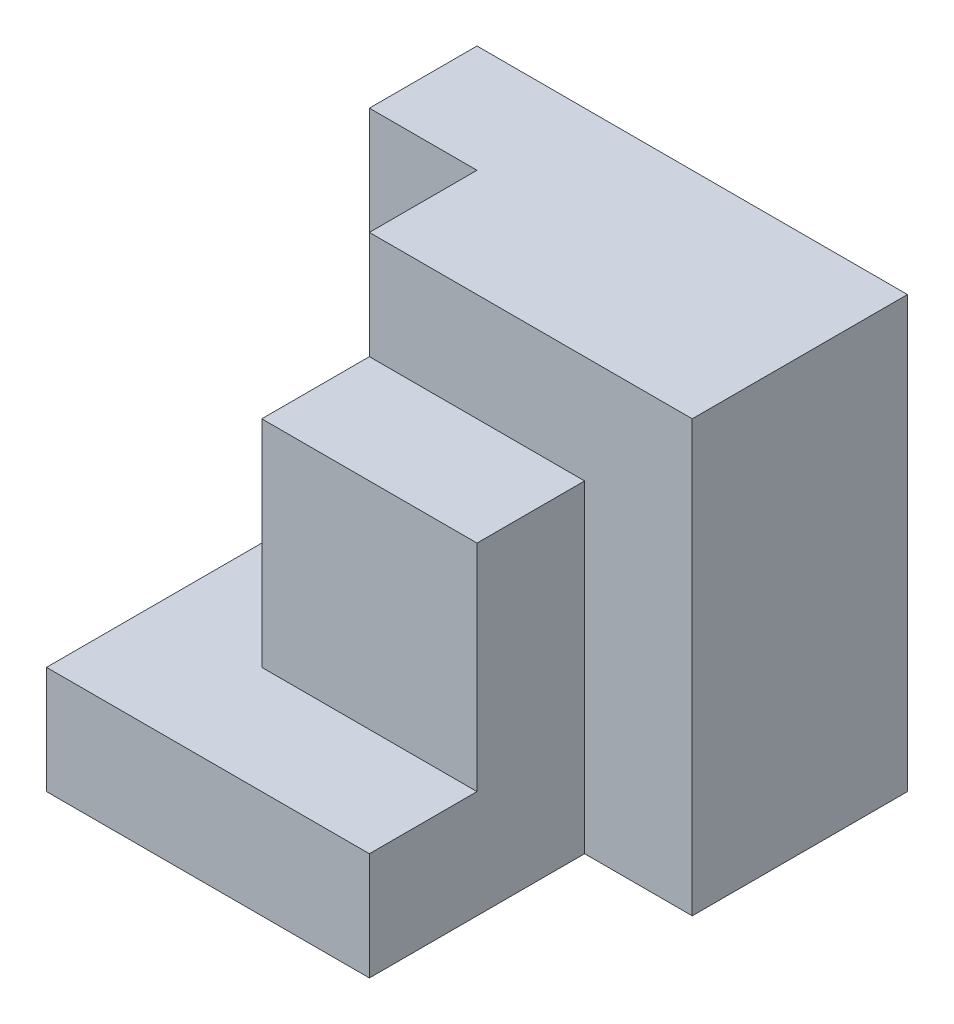
from build123d import *

# Parameters (mm, degrees)
SKETCH1_W           = 40
SKETCH1_H           = 40
BOSS_EXTRUDE1_DEPTH = 40
SKETCH2_W           = 10
SKETCH2_H           = 20
CUT_EXTRUDE1_DEPTH  = 40
SKETCH3_W           = 10
SKETCH3_H           = 10
CUT_EXTRUDE2_DEPTH  = 40
SKETCH4_W           = 10
SKETCH4_H           = 10
CUT_EXTRUDE4_DEPTH  = 20
SKETCH5_W           = 10
SKETCH5_H           = 10
CUT_EXTRUDE5_DEPTH  = 30


with BuildPart() as part:
    # Sketch1 → Boss-Extrude1 (new body)
    with BuildSketch(Plane.XY):
        with Locations((20, 20)):
            Rectangle(SKETCH1_W, SKETCH1_H)
    extrude(amount=BOSS_EXTRUDE1_DEPTH)

    # Sketch2 → Cut-Extrude1 (cut)
    with BuildSketch(Plane(origin=(0, 40, 0), x_dir=(1, 0, 0), z_dir=(0, 1, 0))):
        with Locations((35, -30)):
            Rectangle(SKETCH2_W, SKETCH2_H)
    extrude(amount=-CUT_EXTRUDE1_DEPTH, mode=Mode.SUBTRACT)

    # Sketch3 → Cut-Extrude2 (cut)
    with BuildSketch(Plane.ZY):
        with Locations((25, 35)):
            Rectangle(SKETCH3_W, SKETCH3_H)
        Polygon((40, 10), (40, 40), (30, 40), (30, 30), (30, 10), align=None)
    extrude(amount=-CUT_EXTRUDE2_DEPTH, mode=Mode.SUBTRACT)

    # Sketch4 → Cut-Extrude4 (cut)
    with BuildSketch(Plane(origin=(0, 30, 0), x_dir=(1, 0, 0), z_dir=(0, 1, 0))):
        with Locations((5, -25)):
            Rectangle(SKETCH4_W, SKETCH4_H)
    extrude(amount=-CUT_EXTRUDE4_DEPTH, mode=Mode.SUBTRACT)

    # Sketch5 → Cut-Extrude5 (cut)
    with BuildSketch(Plane(origin=(0, 40, 0), x_dir=(1, 0, 0), z_dir=(0, 1, 0))):
        with Locations((5, -15)):
            Rectangle(SKETCH5_W, SKETCH5_H)
    extrude(amount=-CUT_EXTRUDE5_DEPTH, mode=Mode.SUBTRACT)


solid = part.part
